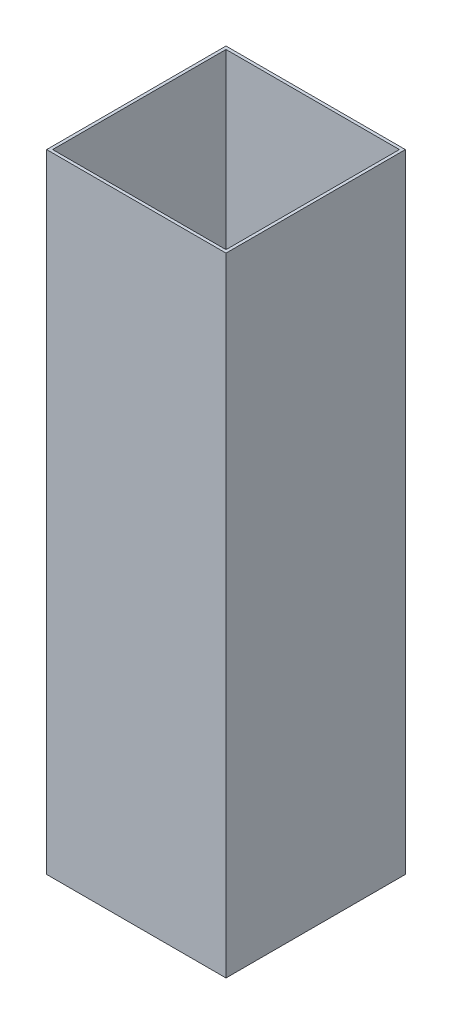
from build123d import *

# Parameters (mm, degrees)
SKETCH1_W      = 600
SKETCH1_H      = 600
SKETCH1_W_2    = 580
SKETCH1_H_2    = 580
EXTRUDE1_DEPTH = 2100


with BuildPart() as part:
    # Sketch1 → Extrude1 (new body)
    with BuildSketch(Plane(origin=(0, 0, 0), x_dir=(1, 0, 0), z_dir=(0, 1, 0))):
        with Locations((300, 300)):
            Rectangle(SKETCH1_W, SKETCH1_H)
        with Locations((300, 300)):
            Rectangle(SKETCH1_W_2, SKETCH1_H_2, mode=Mode.SUBTRACT)
    extrude(amount=EXTRUDE1_DEPTH)


solid = part.part
